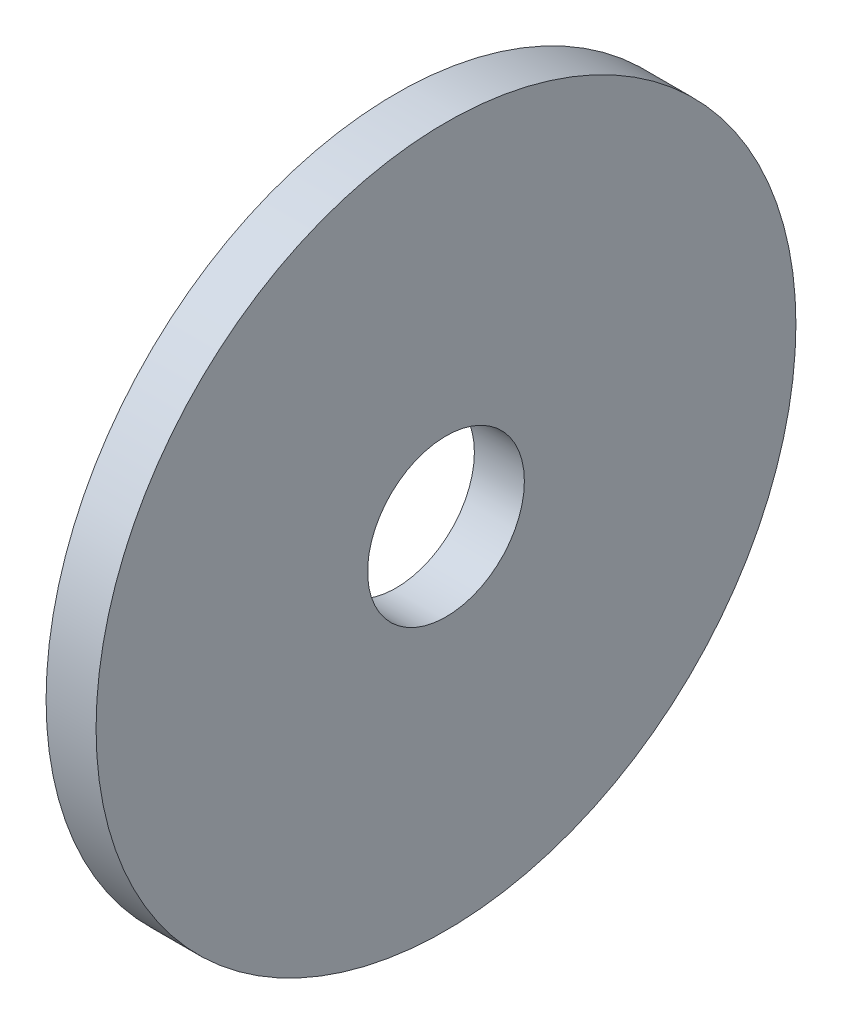
from build123d import *

# Parameters (mm, degrees)
SKETCH1_R                  = 11.1125
BOSS_EXTRUDE1_DEPTH        = 1.5875
F_10_CLEARANCE_HOLE1_D     = 4.9784
F_10_CLEARANCE_HOLE1_DEPTH = 15
F_10_CLEARANCE_HOLE1_TIP   = 1.495662253


with BuildPart() as part:
    # Sketch1 → Boss-Extrude1 (new body)
    with BuildSketch(Plane(origin=(0, 0, 0), x_dir=(0, 0, -1), z_dir=(1, 0, 0))):
        Circle(SKETCH1_R)
    extrude(amount=BOSS_EXTRUDE1_DEPTH)

    # #10 Clearance Hole1
    with Locations(Plane(origin=(1.5875, 0, 0), x_dir=(0, 0, -1), z_dir=(1, 0, 0))):
        with Locations((0, 0)):
            Hole(F_10_CLEARANCE_HOLE1_D / 2, depth=F_10_CLEARANCE_HOLE1_DEPTH)
            with Locations((0, 0, -(F_10_CLEARANCE_HOLE1_DEPTH + F_10_CLEARANCE_HOLE1_TIP / 2))):  # 118° drill point
                Cone(0, F_10_CLEARANCE_HOLE1_D / 2, F_10_CLEARANCE_HOLE1_TIP, mode=Mode.SUBTRACT)


solid = part.part
